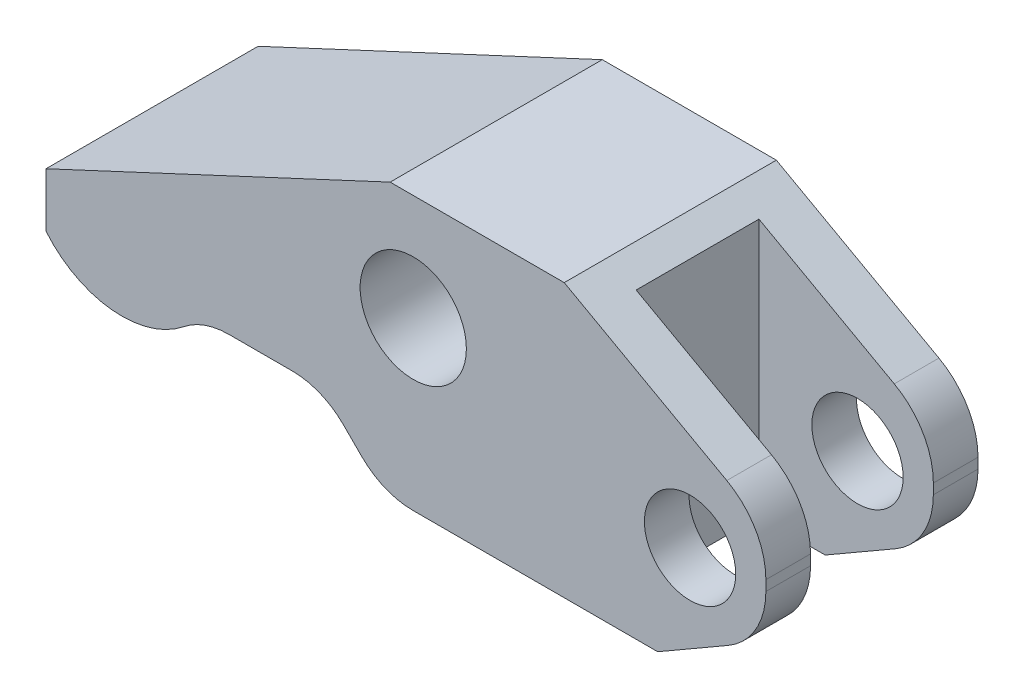
from build123d import *

# Parameters (mm, degrees)
SKETCH2_W               = 47.498
SKETCH2_H               = 13.9954
BOSS_EXTRUDE1_DEPTH     = 9.0043
SKETCH3_R               = 3.01244
SKETCH3_R_2             = 3.5052
CUT_EXTRUDE1_DEPTH      = 7.9977
CUT_EXTRUDE1_DEPTH_BACK = 7.9977
SKETCH5_OUTSIDE_W       = 60.036
SKETCH5_OUTSIDE_H       = 30.546
CUT_EXTRUDE2_DEPTH      = 7.9977
CUT_EXTRUDE2_DEPTH_BACK = 7.9977
CUT_EXTRUDE3_DEPTH      = 7.9977
CUT_EXTRUDE3_DEPTH_BACK = 7.9977
FILLET1_R               = 4.7752
SKETCH7_W               = 11.5062
SKETCH7_H               = 8.1026
CUT_EXTRUDE4_DEPTH      = 10.0043
CUT_EXTRUDE4_DEPTH_BACK = 10.0043


with BuildPart() as part:
    # Sketch2 → Boss-Extrude1 (new body, symmetric)
    with BuildSketch(Plane(origin=(0, 0, 0), x_dir=(1, 0, 0), z_dir=(0, 1, 0))):
        Rectangle(SKETCH2_W, SKETCH2_H)
    extrude(amount=BOSS_EXTRUDE1_DEPTH, both=True)

    # Sketch3 → Cut-Extrude1 (cut, two sides)
    with BuildSketch(Plane.XY) as cut_extrude1_sk:
        with Locations((18.7452, -1.9939)):
            Circle(SKETCH3_R)
        with Locations((0.4826, 1.9939)):
            Circle(SKETCH3_R_2)
    extrude(amount=CUT_EXTRUDE1_DEPTH, mode=Mode.SUBTRACT)
    extrude(cut_extrude1_sk.sketch, amount=-CUT_EXTRUDE1_DEPTH_BACK, mode=Mode.SUBTRACT)

    # Sketch5 outside → Cut-Extrude2 (cut, two sides)
    with BuildSketch(Plane.XY) as cut_extrude2_sk:
        Rectangle(SKETCH5_OUTSIDE_W, SKETCH5_OUTSIDE_H)
        with BuildLine():
            Line((16.610431019, -9.0043), (21.2471, -6.327317915))
            ThreePointArc((21.2471, -6.327317915), (23.078617915, -4.4958), (23.749, -1.9939))
            Line((23.749, -1.9939), (23.749, -1.317979314))
            ThreePointArc((23.749, -1.317979314), (23.056619993, 1.221641146), (21.171090378, 3.058442776))
            Line((21.171090378, 3.058442776), (10.44448, 9.0043))
            Line((10.44448, 9.0043), (-1.0414, 9.0043))
            Line((-1.0414, 9.0043), (-23.749, -1.584427778))
            Line((-23.749, -1.584427778), (-23.749, -9.0043))
            Line((-23.749, -9.0043), (16.610431019, -9.0043))
        make_face(mode=Mode.SUBTRACT)
    extrude(amount=CUT_EXTRUDE2_DEPTH, mode=Mode.SUBTRACT)
    extrude(cut_extrude2_sk.sketch, amount=-CUT_EXTRUDE2_DEPTH_BACK, mode=Mode.SUBTRACT)

    # Sketch6 → Cut-Extrude3 (cut, two sides)
    with BuildSketch(Plane.XY) as cut_extrude3_sk:
        with BuildLine():
            Line((-1.524, -9.0043), (-5.5118, -5.0165))
            Line((-5.5118, -5.0165), (-13.629006931, -5.0165))
            ThreePointArc((-13.629006931, -5.0165), (-18.655709059, -7.50508415), (-23.749, -5.155792182))
            Line((-23.749, -5.155792182), (-23.749, -9.0043))
            Line((-23.749, -9.0043), (-1.524, -9.0043))
        make_face()
    extrude(amount=CUT_EXTRUDE3_DEPTH, mode=Mode.SUBTRACT)
    extrude(cut_extrude3_sk.sketch, amount=-CUT_EXTRUDE3_DEPTH_BACK, mode=Mode.SUBTRACT)

    # Fillet1
    fillet1_edges = [part.edges().sort_by_distance(p)[0] for p in [
        (-13.629006931, -5.0165, 0),
        (-5.5118, -5.0165, 0),
        (-1.524, -9.0043, 0),
    ]]
    fillet(fillet1_edges, radius=FILLET1_R)

    # Sketch7 → Cut-Extrude4 (cut, two sides)
    with BuildSketch(Plane(origin=(0, 0, 0), x_dir=(1, 0, 0), z_dir=(0, 1, 0))) as cut_extrude4_sk:
        with Locations((17.9959, 0)):
            Rectangle(SKETCH7_W, SKETCH7_H)
    extrude(amount=CUT_EXTRUDE4_DEPTH, mode=Mode.SUBTRACT)
    extrude(cut_extrude4_sk.sketch, amount=-CUT_EXTRUDE4_DEPTH_BACK, mode=Mode.SUBTRACT)


solid = part.part
